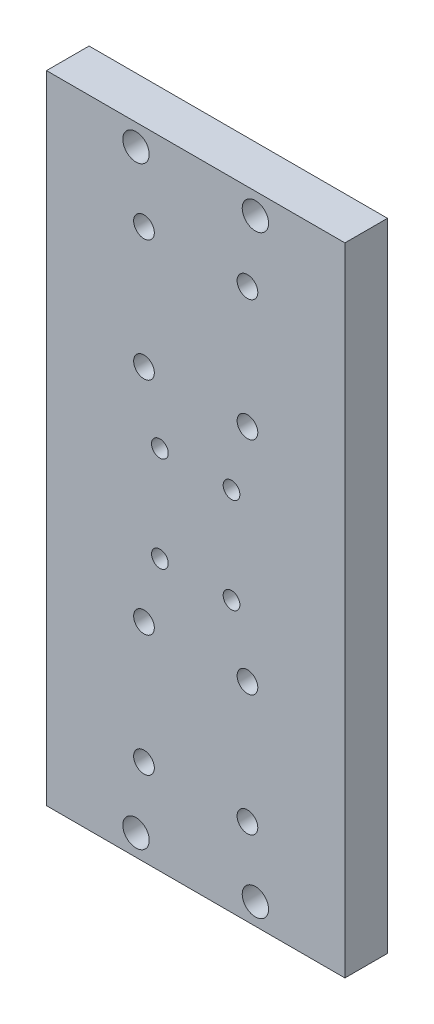
from build123d import *

# Parameters (mm, degrees)
ESBO_O1_W                                   = 75
ESBO_O1_H                                   = 160
RESSALTO_EXTRUS_O1_DEPTH                    = 10.7
FURO_ROSCADO_PARA_CONDU_TE_DE_1_4_281_D     = 6.6294
FURO_ROSCADO_PARA_CONDU_TE_DE_1_4_281_DEPTH = 15
FURO_ROSCADO_PARA_CONDU_TE_DE_1_4_281_TIP   = 1.991672694
FURO_ROSCADO_PARA_CONDU_TE_DE_M5X0_81_D     = 5.2
FURO_ROSCADO_PARA_CONDU_TE_DE_M5X0_81_DEPTH = 15
FURO_ROSCADO_PARA_CONDU_TE_DE_M5X0_81_TIP   = 1.562237609
FURO_ROSCADO_PARA_CONDU_TE_DE_M4X0_71_D     = 4.2
FURO_ROSCADO_PARA_CONDU_TE_DE_M4X0_71_DEPTH = 15
FURO_ROSCADO_PARA_CONDU_TE_DE_M4X0_71_TIP   = 1.2618073
ESBO_O8_R                                   = 4.25
CORTE_EXTRUS_O1_DEPTH                       = 5
ESBO_O9_R                                   = 3.5
CORTE_EXTRUS_O2_DEPTH                       = 4


with BuildPart() as part:
    # Esboço1 → Ressalto-extrusão1 (new body)
    with BuildSketch(Plane.XY):
        Rectangle(ESBO_O1_W, ESBO_O1_H)
    extrude(amount=RESSALTO_EXTRUS_O1_DEPTH)

    # Furo roscado para conduíte de 1/4-281
    with Locations(Plane(origin=(0, 0, 0), x_dir=(-1, 0, 0), z_dir=(0, 0, -1))):
        with Locations((15, 74.65), (-15, 74.65), (15, -74.65), (-15, -74.65)):
            Hole(FURO_ROSCADO_PARA_CONDU_TE_DE_1_4_281_D / 2, depth=FURO_ROSCADO_PARA_CONDU_TE_DE_1_4_281_DEPTH)
            with Locations((0, 0, -(FURO_ROSCADO_PARA_CONDU_TE_DE_1_4_281_DEPTH + FURO_ROSCADO_PARA_CONDU_TE_DE_1_4_281_TIP / 2))):  # 118° drill point
                Cone(0, FURO_ROSCADO_PARA_CONDU_TE_DE_1_4_281_D / 2, FURO_ROSCADO_PARA_CONDU_TE_DE_1_4_281_TIP, mode=Mode.SUBTRACT)

    # Furo roscado para conduíte de M5x0.81
    with Locations(Plane(origin=(0, 0, 0), x_dir=(-1, 0, 0), z_dir=(0, 0, -1))):
        with Locations((13, 58.25), (13, 27.75), (-13, 27.75), (-13, 58.25), (13, -27.75), (-13, -27.75), (13, -58.25), (-13, -58.25)):
            Hole(FURO_ROSCADO_PARA_CONDU_TE_DE_M5X0_81_D / 2, depth=FURO_ROSCADO_PARA_CONDU_TE_DE_M5X0_81_DEPTH)
            with Locations((0, 0, -(FURO_ROSCADO_PARA_CONDU_TE_DE_M5X0_81_DEPTH + FURO_ROSCADO_PARA_CONDU_TE_DE_M5X0_81_TIP / 2))):  # 118° drill point
                Cone(0, FURO_ROSCADO_PARA_CONDU_TE_DE_M5X0_81_D / 2, FURO_ROSCADO_PARA_CONDU_TE_DE_M5X0_81_TIP, mode=Mode.SUBTRACT)

    # Furo roscado para conduíte de M4x0.71
    with Locations(Plane(origin=(0, 0, 0), x_dir=(-1, 0, 0), z_dir=(0, 0, -1))):
        with Locations((9, 12), (-9, 12), (9, -12), (-9, -12)):
            Hole(FURO_ROSCADO_PARA_CONDU_TE_DE_M4X0_71_D / 2, depth=FURO_ROSCADO_PARA_CONDU_TE_DE_M4X0_71_DEPTH)
            with Locations((0, 0, -(FURO_ROSCADO_PARA_CONDU_TE_DE_M4X0_71_DEPTH + FURO_ROSCADO_PARA_CONDU_TE_DE_M4X0_71_TIP / 2))):  # 118° drill point
                Cone(0, FURO_ROSCADO_PARA_CONDU_TE_DE_M4X0_71_D / 2, FURO_ROSCADO_PARA_CONDU_TE_DE_M4X0_71_TIP, mode=Mode.SUBTRACT)

    # Esboço8 → Corte-extrusão1 (cut)
    with BuildSketch(Plane(origin=(0, 0, 0), x_dir=(-1, 0, 0), z_dir=(0, 0, -1))):
        with Locations((-13, 58.25)):
            Circle(ESBO_O8_R)
        with Locations((-13, 27.75)):
            Circle(ESBO_O8_R)
        with Locations((13, 27.75)):
            Circle(ESBO_O8_R)
        with Locations((13, 58.25)):
            Circle(ESBO_O8_R)
        with Locations((13, -27.75)):
            Circle(ESBO_O8_R)
        with Locations((-13, -27.75)):
            Circle(ESBO_O8_R)
        with Locations((13, -58.25)):
            Circle(ESBO_O8_R)
        with Locations((-13, -58.25)):
            Circle(ESBO_O8_R)
    extrude(amount=-CORTE_EXTRUS_O1_DEPTH, mode=Mode.SUBTRACT)

    # Esboço9 → Corte-extrusão2 (cut)
    with BuildSketch(Plane(origin=(0, 0, 0), x_dir=(-1, 0, 0), z_dir=(0, 0, -1))):
        with Locations((-9, 12)):
            Circle(ESBO_O9_R)
        with Locations((9, 12)):
            Circle(ESBO_O9_R)
        with Locations((-9, -12)):
            Circle(ESBO_O9_R)
        with Locations((9, -12)):
            Circle(ESBO_O9_R)
    extrude(amount=-CORTE_EXTRUS_O2_DEPTH, mode=Mode.SUBTRACT)


solid = part.part
